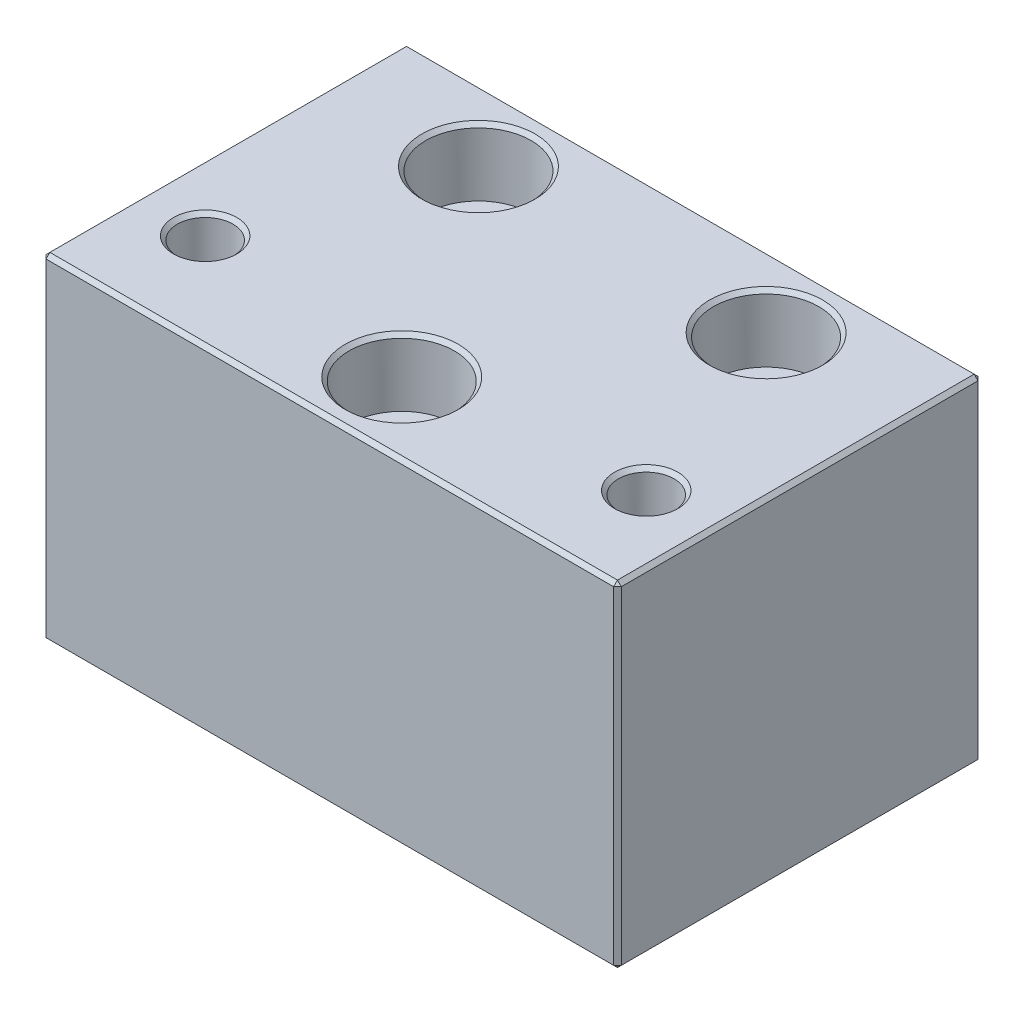
from build123d import *

# Parameters (mm, degrees)
SKETCH1_W           = 60
SKETCH1_H           = 38
BOSS_EXTRUDE1_DEPTH = 35
SKETCH2_R           = 2.9
SKETCH2_R_2         = 3.05
CUT_EXTRUDE1_DEPTH  = 36
SKETCH3_R           = 5.5
CUT_EXTRUDE2_DEPTH  = 7
CHAMFER1_SIZE       = 0.4


with BuildPart() as part:
    # Sketch1 → Boss-Extrude1 (new body)
    with BuildSketch(Plane(origin=(0, 0, 0), x_dir=(1, 0, 0), z_dir=(0, 1, 0))):
        Rectangle(SKETCH1_W, SKETCH1_H)
    extrude(amount=BOSS_EXTRUDE1_DEPTH)

    # Sketch2 → Cut-Extrude1 (cut, through all)
    with BuildSketch(Plane(origin=(0, 35, 0), x_dir=(1, 0, 0), z_dir=(0, 1, 0))):
        with Locations((-23, -9)):
            Circle(SKETCH2_R)
        with Locations((23, -9)):
            Circle(SKETCH2_R)
        with Locations((-15, 11.5)):
            Circle(SKETCH2_R_2)
        with Locations((0, -11.5)):
            Circle(SKETCH2_R_2)
        with Locations((15, 11.5)):
            Circle(SKETCH2_R_2)
    extrude(amount=-CUT_EXTRUDE1_DEPTH, mode=Mode.SUBTRACT)

    # Sketch3 → Cut-Extrude2 (cut)
    with BuildSketch(Plane(origin=(0, 35, 0), x_dir=(1, 0, 0), z_dir=(0, 1, 0))):
        with Locations((-15, 11.5)):
            Circle(SKETCH3_R)
        with Locations((15, 11.5)):
            Circle(SKETCH3_R)
        with Locations((0, -11.5)):
            Circle(SKETCH3_R)
    extrude(amount=-CUT_EXTRUDE2_DEPTH, mode=Mode.SUBTRACT)

    # Chamfer1
    chamfer1_edges = [part.edges().sort_by_distance(p)[0] for p in [
        (30, 35, 0),
        (0, 35, -19),
        (-25.9, 35, 9),
        (20.1, 35, 9),
        (-20.5, 35, -11.5),
        (9.5, 35, -11.5),
        (-5.5, 35, 11.5),
        (-30, 35, 0),
        (0, 0, -19),
        (30, 0, 0),
        (0, 0, 19),
        (-30, 0, 0),
        (-30, 17.5, -19),
        (30, 17.5, -19),
        (30, 17.5, 19),
        (-30, 17.5, 19),
        (0, 35, 19),
    ]]
    chamfer(chamfer1_edges, length=CHAMFER1_SIZE)


solid = part.part
